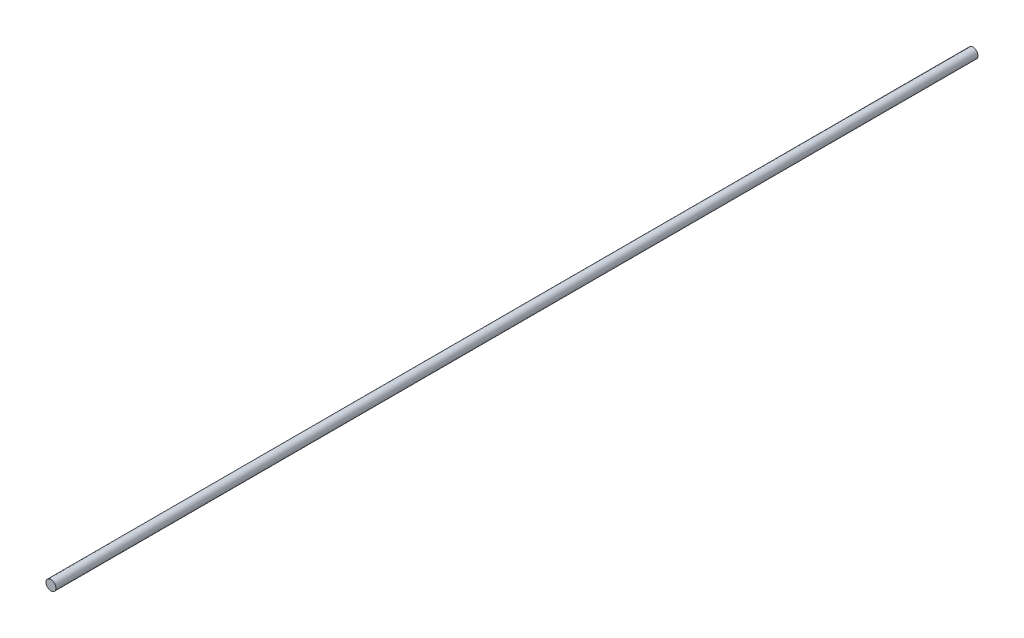
from build123d import *

# Parameters (mm, degrees)
SKETCH1_R           = 27.5
BOSS_EXTRUDE1_DEPTH = 5100
SCALE1_SCALE        = 0.1


with BuildPart() as part:
    # Sketch1 → Boss-Extrude1 (new body)
    with BuildSketch(Plane.XY):
        Circle(SKETCH1_R)
    extrude(amount=BOSS_EXTRUDE1_DEPTH)


with BuildPart() as part_1:
    # Scale1: scaled about (0, 0, 2550)
    add(part.part.scale(SCALE1_SCALE).moved(Location((0, 0, 2295))))


solid = part_1.part
